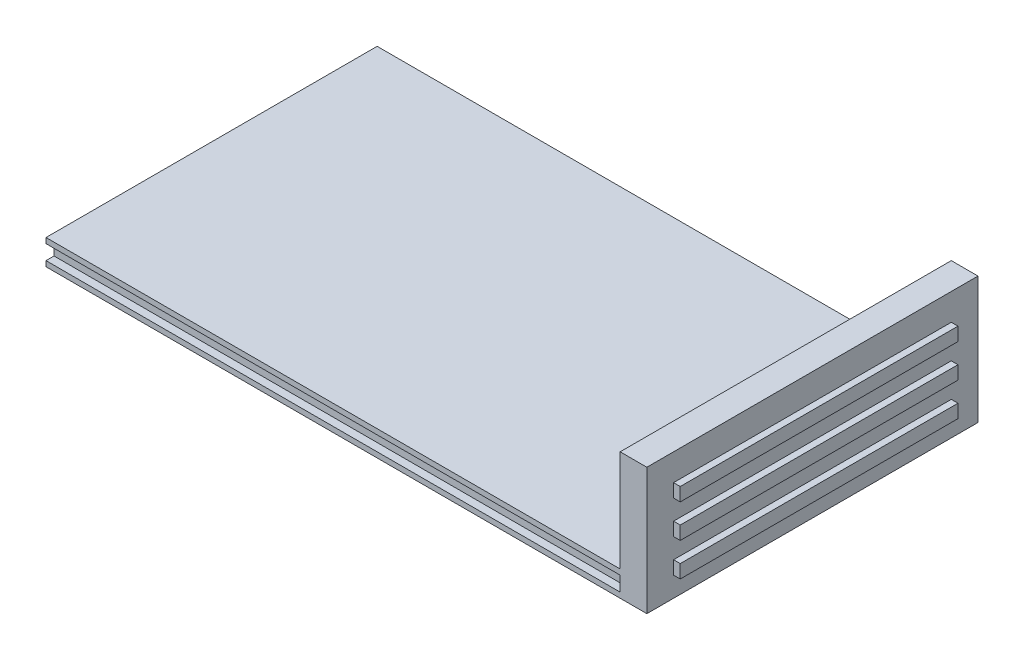
from build123d import *

# Parameters (mm, degrees)
SKETCH1_W           = 90
SKETCH1_H           = 49.6
BOSS_EXTRUDE1_DEPTH = 3.8
SKETCH2_W           = 1.2
SKETCH2_H           = 2.2
CUT_EXTRUDE1_DEPTH  = 91
SKETCH3_W           = 4
SKETCH3_H           = 49.6
BOSS_EXTRUDE2_DEPTH = 19
SKETCH4_W           = 41.6
SKETCH4_H           = 2
BOSS_EXTRUDE3_DEPTH = 1
LPATTERN1_COUNT     = 3
LPATTERN1_PITCH     = 5


with BuildPart() as part:
    # Sketch1 → Boss-Extrude1 (new body)
    with BuildSketch(Plane(origin=(0, 0, 0), x_dir=(1, 0, 0), z_dir=(0, 1, 0))):
        Rectangle(SKETCH1_W, SKETCH1_H)
    extrude(amount=BOSS_EXTRUDE1_DEPTH)

    # Sketch2 → Cut-Extrude1 (cut, through all)
    with BuildSketch(Plane(origin=(45, 0, 0), x_dir=(0, 0, -1), z_dir=(1, 0, 0))):
        with Locations((-24.2, 1.9)):
            Rectangle(SKETCH2_W, SKETCH2_H)
    cut_extrude1 = extrude(amount=-CUT_EXTRUDE1_DEPTH, mode=Mode.SUBTRACT)

    # Mirror1: Cut-Extrude1 across plane
    add(cut_extrude1.mirror(Plane.XY), mode=Mode.SUBTRACT)

    # Sketch3 → Boss-Extrude2 (add)
    with BuildSketch(Plane.XZ):
        with Locations((43, 0)):
            Rectangle(SKETCH3_W, SKETCH3_H)
    extrude(amount=-BOSS_EXTRUDE2_DEPTH)

    # Sketch4 → Boss-Extrude3 (add)
    with BuildSketch(Plane(origin=(45, 0, 0), x_dir=(0, 0, -1), z_dir=(1, 0, 0))):
        with Locations((0, 14)):
            Rectangle(SKETCH4_W, SKETCH4_H)
    boss_extrude3 = extrude(amount=BOSS_EXTRUDE3_DEPTH)

    # LPattern1: Boss-Extrude3 ×3
    with Locations(*[(0, -i * LPATTERN1_PITCH, 0) for i in range(1, LPATTERN1_COUNT)]):
        add(boss_extrude3)


solid = part.part
